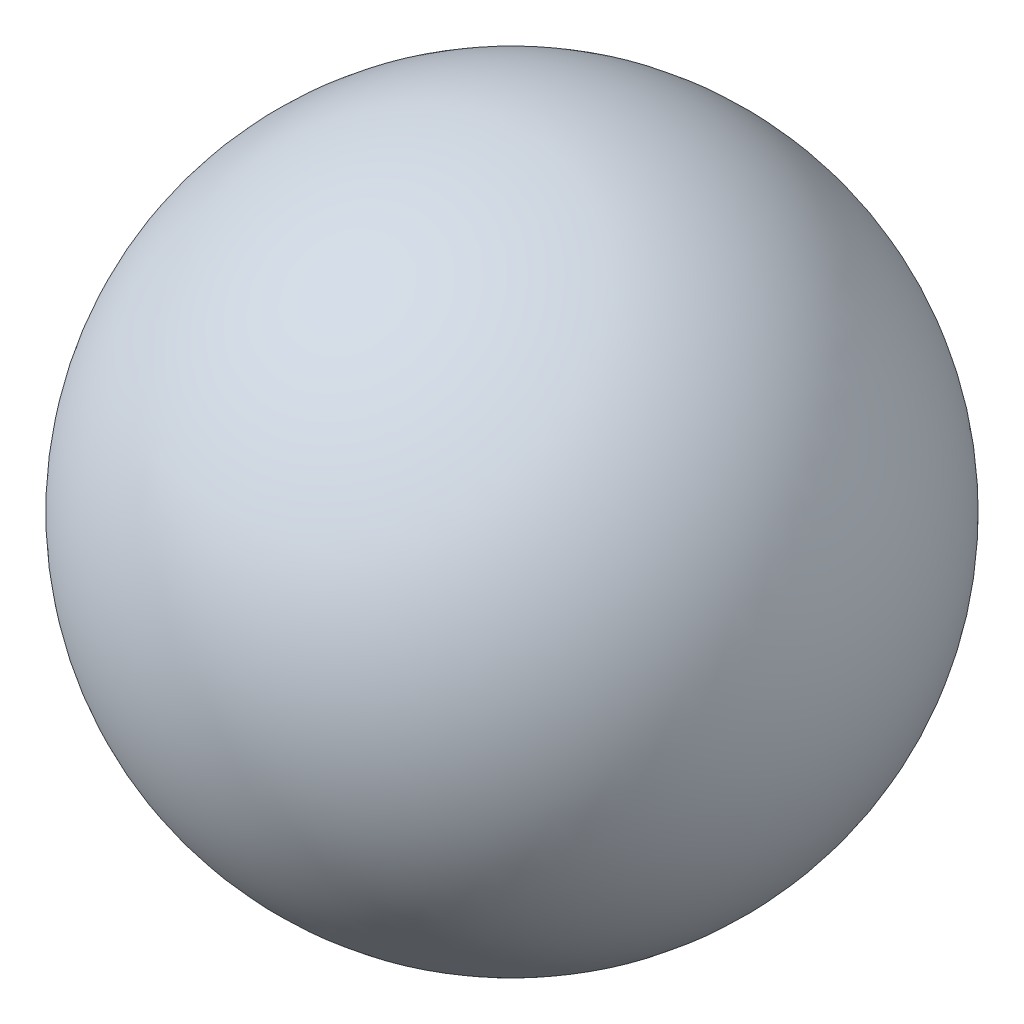
from build123d import *


with BuildPart() as part:
    # Sketch3 → Revolve1 (revolve)
    with BuildSketch(Plane.XY):
        with BuildLine():
            Line((0, 0), (0, 15))
            ThreePointArc((0, 15), (7.5, 7.5), (0, 0))
        make_face()
    revolve(axis=Axis((0, 0, 0), (0, 1, 0)))


solid = part.part
